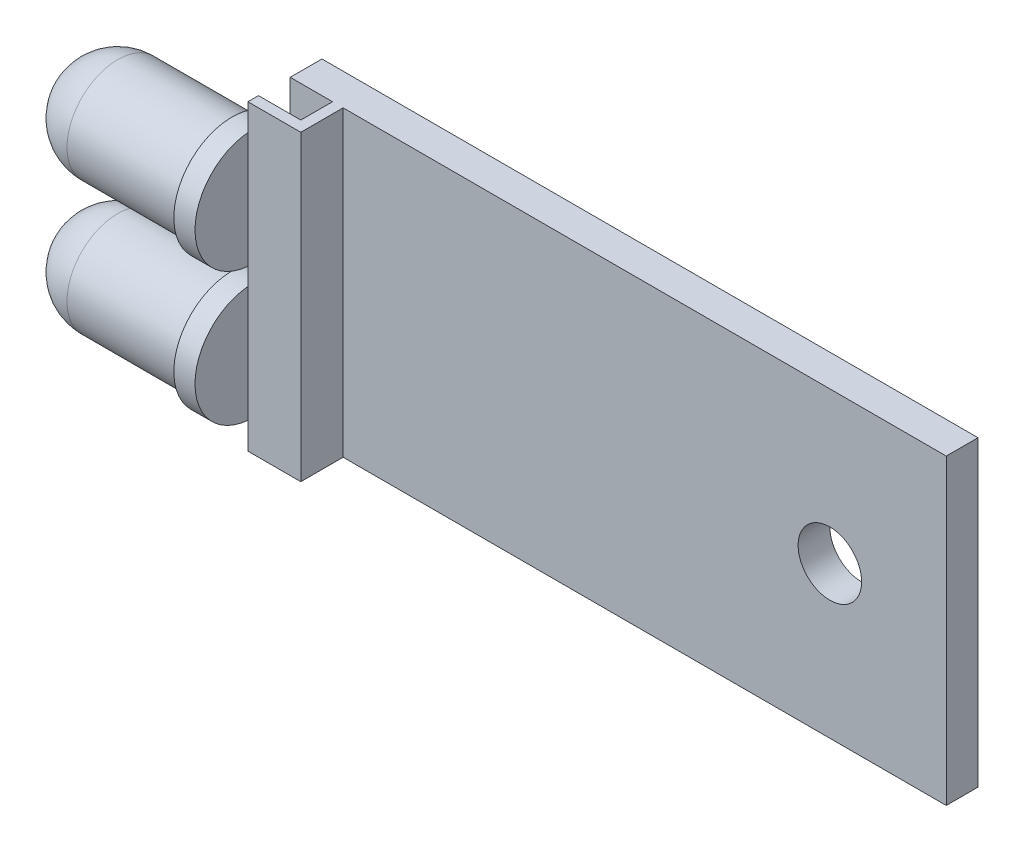
from build123d import *

# Parameters (mm, degrees)
SKETCH1_W           = 31
SKETCH1_H           = 14.3
BOSS_EXTRUDE1_DEPTH = 1.5
BOSS_EXTRUDE2_DEPTH = 14.3
SKETCH5_R           = 1.5
CUT_EXTRUDE1_DEPTH  = 1.5


with BuildPart() as part:
    # Sketch1 → Boss-Extrude1 (new body)
    with BuildSketch(Plane.XY):
        with Locations((15.5, 0)):
            Rectangle(SKETCH1_W, SKETCH1_H)
    extrude(amount=BOSS_EXTRUDE1_DEPTH)

    # Sketch2 → Boss-Extrude2 (add, through all)
    with BuildSketch(Plane.XZ.offset(7.15)):
        Polygon((2.5, 1.5), (2.5, 3.5), (0, 3.5), (0, 3), (2, 3), (2, 1.5), align=None)
    extrude(amount=-BOSS_EXTRUDE2_DEPTH)

    # Sketch4 → Revolve1 (revolve)
    with BuildSketch(Plane.XZ.offset(3.15)):
        with BuildLine():
            Line((0, 3.5), (0, 6))
            Line((0, 6), (-1, 6))
            Line((-1, 6), (-1, 5.65))
            Line((-1, 5.65), (-6.4, 5.65))
            ThreePointArc((-6.4, 5.65), (-8.097056275, 4.947056275), (-8.8, 3.25))
            Line((-8.8, 3.25), (0, 3.25))
            Line((0, 3.25), (0, 3.5))
        make_face()
    revolve1 = revolve(axis=Axis((0, -3.15, 3.25), (-1, 0, 0)))

    # Mirror1: Revolve1 across plane
    add(revolve1.mirror(Plane.ZX))

    # Sketch5 → Cut-Extrude1 (cut)
    with BuildSketch(Plane.XY.offset(1.5)):
        with Locations((25.5, 0)):
            Circle(SKETCH5_R)
    extrude(amount=-CUT_EXTRUDE1_DEPTH, mode=Mode.SUBTRACT)


solid = part.part
